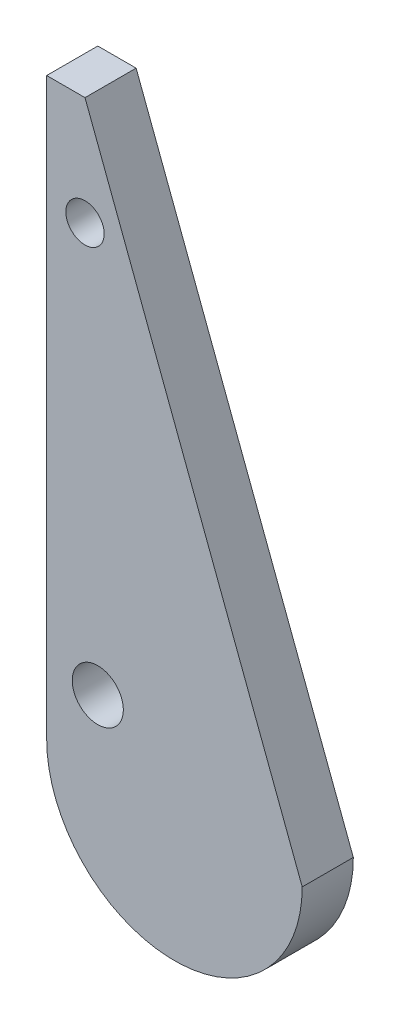
from build123d import *

# Parameters (mm, degrees)
BOSS_EXTRUDE1_DEPTH = 4
SKETCH2_R           = 2
SKETCH2_R_2         = 1.5
CUT_EXTRUDE1_DEPTH  = 4


with BuildPart() as part:
    # Sketch1 → Boss-Extrude1 (new body)
    with BuildSketch(Plane.XY):
        with BuildLine():
            Line((0, 0), (0, 45))
            Line((0, 45), (3, 45))
            Line((3, 45), (20, 0))
            ThreePointArc((20, 0), (10, -10), (0, 0))
        make_face()
    extrude(amount=BOSS_EXTRUDE1_DEPTH)

    # Sketch2 → Cut-Extrude1 (cut)
    with BuildSketch(Plane.XY.offset(4)):
        with Locations((4, 5)):
            Circle(SKETCH2_R)
        with Locations((3, 36.511049315)):
            Circle(SKETCH2_R_2)
    extrude(amount=-CUT_EXTRUDE1_DEPTH, mode=Mode.SUBTRACT)


solid = part.part
